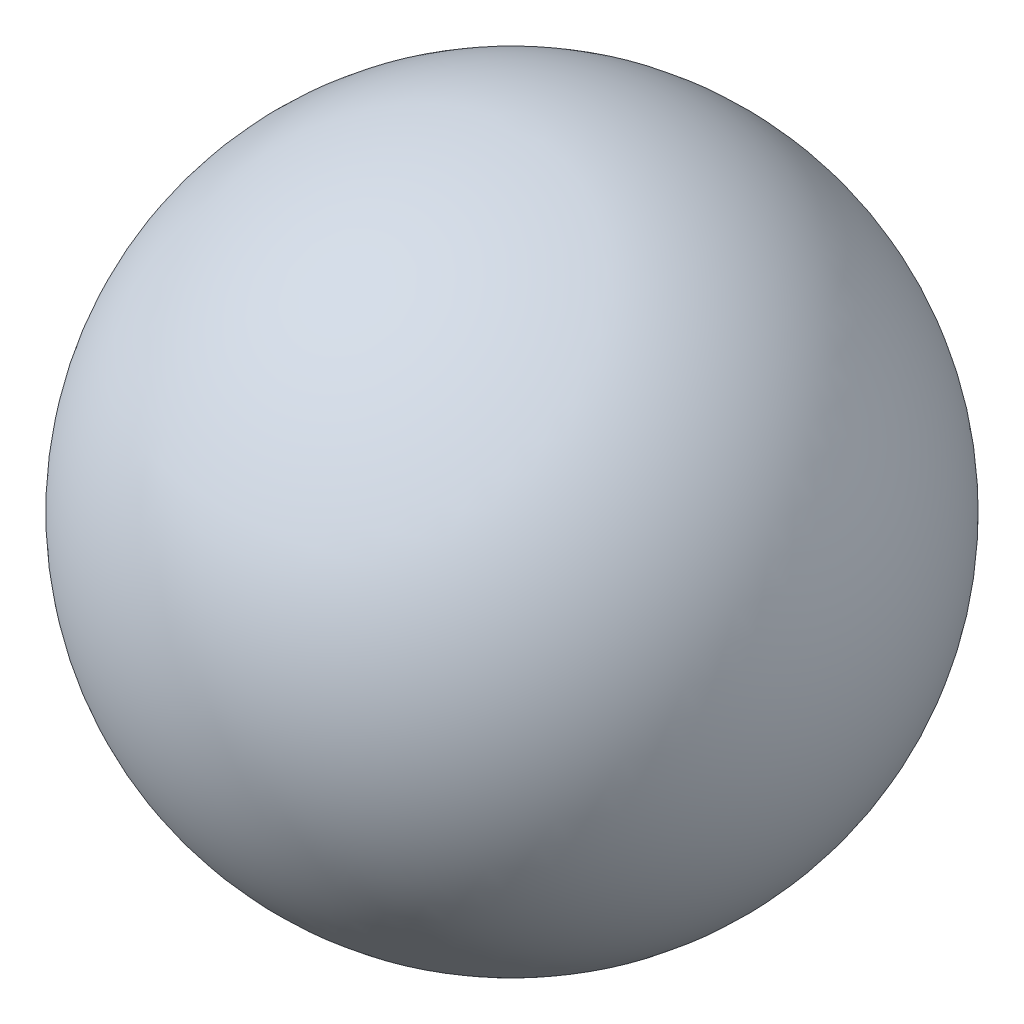
from build123d import *


with BuildPart() as part:
    # Sketch1 one side → Revolve1 (revolve)
    with BuildSketch(Plane.XY):
        with BuildLine():
            Line((0, -20), (0, 20))
            ThreePointArc((0, 20), (-20, 0), (0, -20))
        make_face()
    revolve(axis=Axis((0, -20, 0), (0, 1, 0)))


solid = part.part
